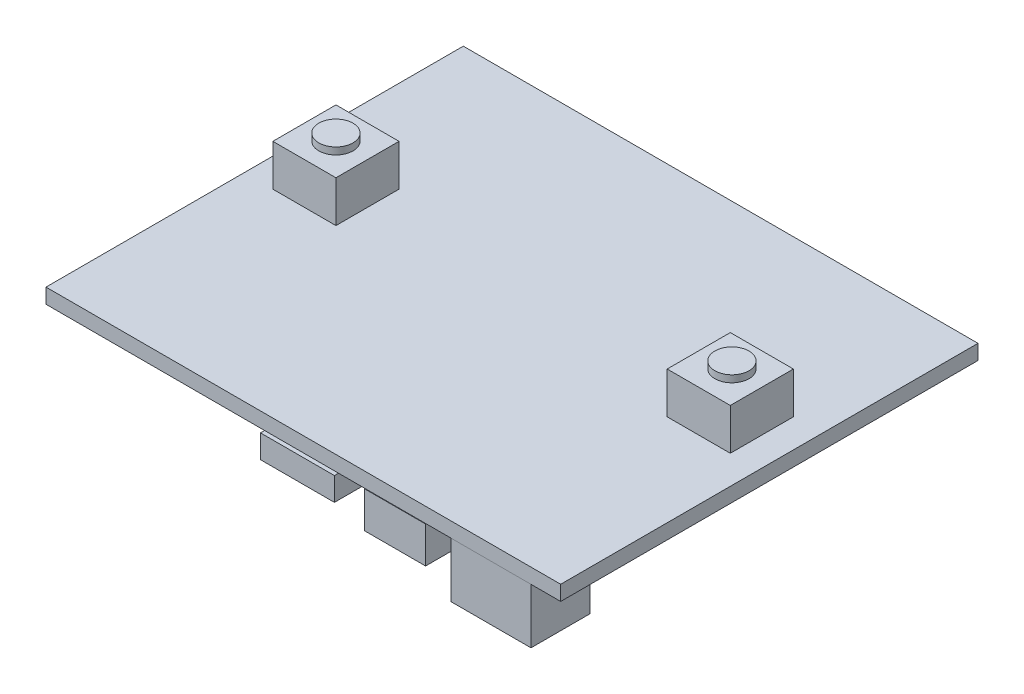
from build123d import *

# Parameters (mm, degrees)
ESQUISSE1_W        = 51.8
ESQUISSE1_H        = 42
BOSS_EXTRU_1_DEPTH = 1.5
ESQUISSE2_W        = 6.35
ESQUISSE2_H        = 6.35
BOSS_EXTRU_2_DEPTH = 4.17
ESQUISSE3_R        = 1.72
BOSS_EXTRU_3_DEPTH = 0.7
ESQUISSE7_W        = 6.16
ESQUISSE7_H        = 6.16
BOSS_EXTRU_4_DEPTH = 3.66
ESQUISSE5_W        = 7.44
ESQUISSE5_H        = 5.9
BOSS_EXTRU_5_DEPTH = 2.34
ESQUISSE6_W        = 8.04
ESQUISSE6_H        = 5.92
BOSS_EXTRU_6_DEPTH = 5.55
ESQUISSE8_R        = 1.72
BOSS_EXTRU_7_DEPTH = 0.8


with BuildPart() as part:
    # Esquisse1 → Boss.-Extru.1 (new body)
    with BuildSketch(Plane(origin=(0, 0, 0), x_dir=(1, 0, 0), z_dir=(0, 1, 0))):
        with Locations((25.9, 21)):
            Rectangle(ESQUISSE1_W, ESQUISSE1_H)
    extrude(amount=-BOSS_EXTRU_1_DEPTH)

    # Esquisse2 → Boss.-Extru.2 (add)
    with BuildSketch(Plane(origin=(0, 0, 0), x_dir=(1, 0, 0), z_dir=(0, 1, 0))):
        with Locations((45.745, 23.125)):
            Rectangle(ESQUISSE2_W, ESQUISSE2_H)
        with Locations((6.055, 23.125)):
            Rectangle(ESQUISSE2_W, ESQUISSE2_H)
    extrude(amount=BOSS_EXTRU_2_DEPTH)

    # Esquisse3 → Boss.-Extru.3 (add)
    with BuildSketch(Plane(origin=(0, 4.17, 0), x_dir=(1, 0, 0), z_dir=(0, 1, 0))):
        with Locations((6.030530149, 23.148945457)):
            Circle(ESQUISSE3_R)
        with Locations((45.817014074, 23.217873135)):
            Circle(ESQUISSE3_R)
    extrude(amount=BOSS_EXTRU_3_DEPTH)

    # Esquisse7 → Boss.-Extru.4 (add)
    with BuildSketch(Plane.XZ.offset(1.5)):
        with Locations((35.174690325, -3.02873507)):
            Rectangle(ESQUISSE7_W, ESQUISSE7_H)
    extrude(amount=BOSS_EXTRU_4_DEPTH)

    # Esquisse5 → Boss.-Extru.5 (add)
    with BuildSketch(Plane.XZ.offset(1.5)):
        with Locations((25.72, -2.536674281)):
            Rectangle(ESQUISSE5_W, ESQUISSE5_H)
    extrude(amount=BOSS_EXTRU_5_DEPTH)

    # Esquisse6 → Boss.-Extru.6 (add)
    with BuildSketch(Plane.XZ.offset(1.5)):
        with Locations((44.78, -2.971238989)):
            Rectangle(ESQUISSE6_W, ESQUISSE6_H)
    extrude(amount=BOSS_EXTRU_6_DEPTH)

    # Esquisse8 → Boss.-Extru.7 (add)
    with BuildSketch(Plane.XZ.offset(5.16)):
        with Locations((35.263038033, -2.994330068)):
            Circle(ESQUISSE8_R)
    extrude(amount=BOSS_EXTRU_7_DEPTH)


solid = part.part
